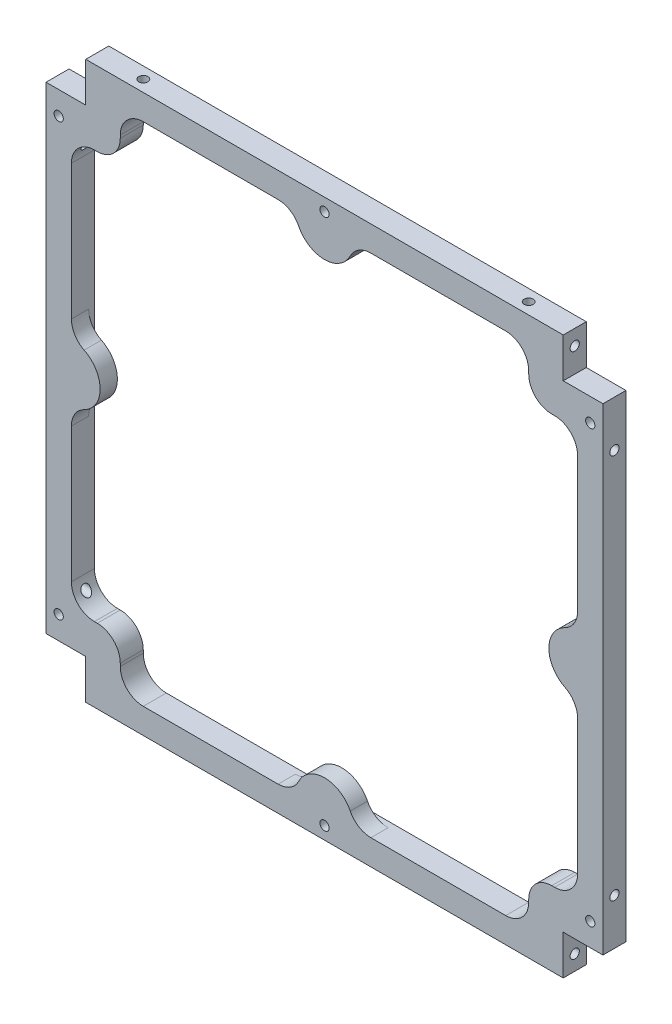
from build123d import *

# Parameters (mm, degrees)
SKETCH3_W                  = 100
SKETCH3_H                  = 100
BOSS_EXTRUDE2_DEPTH        = 4
SKETCH4_W                  = 8.5
SKETCH4_H                  = 8.5
CUT_EXTRUDE1_DEPTH         = 142.477913471
CUT_EXTRUDE2_DEPTH         = 142.477913471
FILLET4_R                  = 4
FILLET6_R                  = 4
BOSS_EXTRUDE3_DEPTH        = 3
M2X0_4_TAPPED_HOLE1_D      = 1.6
M2X0_4_TAPPED_HOLE1_DEPTH  = 5.2
M2X0_4_TAPPED_HOLE1_TIP    = 0.480688495
M2X0_4_TAPPED_HOLE2_REACH  = 143.478
M2X0_4_TAPPED_HOLE2_BORE_R = 0.8
M2X0_4_TAPPED_HOLE3_D      = 1.6
M2X0_4_TAPPED_HOLE3_DEPTH  = 8.52
M2X0_4_TAPPED_HOLE3_TIP    = 0.480688495
M2X0_4_TAPPED_HOLE13_D     = 1.6
M2X0_4_TAPPED_HOLE5_D      = 1.6
M2X0_4_TAPPED_HOLE5_DEPTH  = 6
M2X0_4_TAPPED_HOLE5_TIP    = 0.480688495
FILLET7_R                  = 4
FILLET8_R                  = 4
M2X0_4_TAPPED_HOLE9_D      = 1.6
M2X0_4_TAPPED_HOLE9_DEPTH  = 6
M2X0_4_TAPPED_HOLE9_TIP    = 0.480688495
M2X0_4_TAPPED_HOLE10_D     = 1.6
M2X0_4_TAPPED_HOLE10_DEPTH = 6
M2X0_4_TAPPED_HOLE10_TIP   = 0.480688495
SKETCH33_W                 = 83
SKETCH33_H                 = 1.6
SKETCH33_W_2               = 1.6
SKETCH33_H_2               = 83
CUT_EXTRUDE3_DEPTH         = 10
M2X0_4_TAPPED_HOLE11_D     = 1.6
M2X0_4_TAPPED_HOLE11_DEPTH = 6
M2X0_4_TAPPED_HOLE11_TIP   = 0.480688495
M2X0_4_TAPPED_HOLE12_D     = 1.6
M2X0_4_TAPPED_HOLE12_DEPTH = 6
M2X0_4_TAPPED_HOLE12_TIP   = 0.480688495


with BuildPart() as part:
    # Sketch3 → Boss-Extrude2 (new body)
    with BuildSketch(Plane.XY):
        with Locations((50, -50)):
            Rectangle(SKETCH3_W, SKETCH3_H)
    extrude(amount=BOSS_EXTRUDE2_DEPTH)

    # Sketch4 → Cut-Extrude1 (cut, through all)
    with BuildSketch(Plane(origin=(0, 0, 0), x_dir=(-1, 0, 0), z_dir=(0, 0, -1))):
        with Locations((-4.25, -95.75)):
            Rectangle(SKETCH4_W, SKETCH4_H)
        with Locations((-4.25, -4.25)):
            Rectangle(SKETCH4_W, SKETCH4_H)
        with Locations((-95.75, -4.25)):
            Rectangle(SKETCH4_W, SKETCH4_H)
        with Locations((-95.75, -95.75)):
            Rectangle(SKETCH4_W, SKETCH4_H)
    extrude(amount=-CUT_EXTRUDE1_DEPTH, mode=Mode.SUBTRACT)

    # Sketch5 → Cut-Extrude2 (cut, through all)
    with BuildSketch(Plane(origin=(0, 0, 0), x_dir=(-1, 0, 0), z_dir=(0, 0, -1))):
        Polygon((-94, -14.5), (-85.5, -14.5), (-85.5, -6), (-14.5, -6), (-14.5, -14.5), (-6, -14.5), (-6, -85.5), (-14.5, -85.5), (-14.5, -94), (-85.5, -94), (-85.5, -85.5), (-94, -85.5), align=None)
    extrude(amount=-CUT_EXTRUDE2_DEPTH, mode=Mode.SUBTRACT)

    # Fillet4
    fillet4_edges = [part.edges().sort_by_distance(p)[0] for p in [
        (85.5, -14.5, 2),
        (14.5, -14.5, 2),
        (14.5, -85.5, 2),
        (85.5, -85.5, 2),
    ]]
    fillet(fillet4_edges, radius=FILLET4_R)

    # Fillet6
    fillet6_edges = [part.edges().sort_by_distance(p)[0] for p in [
        (94, -85.5, 2),
        (94, -14.5, 2),
        (85.5, -6, 2),
        (14.5, -6, 2),
        (6, -14.5, 2),
        (6, -85.5, 2),
        (14.5, -94, 2),
        (85.5, -94, 2),
    ]]
    fillet(fillet6_edges, radius=FILLET6_R)

    # Sketch6 → Boss-Extrude3 (add)
    with BuildSketch(Plane.XY.offset(4)):
        with BuildLine():
            Line((6, -45), (6, -55))
            ThreePointArc((6, -55), (11, -50), (6, -45))
        make_face()
        with BuildLine():
            Line((94, -45), (94, -55))
            ThreePointArc((94, -55), (89, -50), (94, -45))
        make_face()
        with BuildLine():
            Line((45, -6), (55, -6))
            ThreePointArc((55, -6), (50, -11), (45, -6))
        make_face()
        with BuildLine():
            Line((45, -94), (55, -94))
            ThreePointArc((55, -94), (50, -89), (45, -94))
        make_face()
    extrude(amount=-BOSS_EXTRUDE3_DEPTH)

    # M2x0.4 Tapped Hole1
    with Locations(Plane.XY.offset(4)):
        with Locations((50, -3.8), (3.8, -12.5), (50, -96.2), (96.2, -87.5), (3.8, -87.5), (96.2, -12.5)):
            Hole(M2X0_4_TAPPED_HOLE1_D / 2, depth=M2X0_4_TAPPED_HOLE1_DEPTH)
            with Locations((0, 0, -(M2X0_4_TAPPED_HOLE1_DEPTH + M2X0_4_TAPPED_HOLE1_TIP / 2))):  # 118° drill point
                Cone(0, M2X0_4_TAPPED_HOLE1_D / 2, M2X0_4_TAPPED_HOLE1_TIP, mode=Mode.SUBTRACT)

    # M2x0.4 Tapped Hole2 bore → M2x0.4 Tapped Hole2 (cut, up to next)
    with BuildSketch(Plane(origin=(0, 0, 0), x_dir=(1, 0, 0), z_dir=(0, 1, 0)), mode=Mode.PRIVATE) as m2x0_4_tapped_hole2_sk1:
        with Locations((83.5, -2)):
            Circle(M2X0_4_TAPPED_HOLE2_BORE_R)
    m2x0_4_tapped_hole2_tool1 = extrude(m2x0_4_tapped_hole2_sk1.sketch, amount=-M2X0_4_TAPPED_HOLE2_REACH, mode=Mode.PRIVATE) & part.part
    # M2x0.4 Tapped Hole2 bore → M2x0.4 Tapped Hole2 (cut, up to next)
    with BuildSketch(Plane(origin=(0, 0, 0), x_dir=(1, 0, 0), z_dir=(0, 1, 0)), mode=Mode.PRIVATE) as m2x0_4_tapped_hole2_sk2:
        with Locations((16.5, -2)):
            Circle(M2X0_4_TAPPED_HOLE2_BORE_R)
    m2x0_4_tapped_hole2_tool2 = extrude(m2x0_4_tapped_hole2_sk2.sketch, amount=-M2X0_4_TAPPED_HOLE2_REACH, mode=Mode.PRIVATE) & part.part
    add(m2x0_4_tapped_hole2_tool1.solids().sort_by_distance((83.5, 0, 2))[0], mode=Mode.SUBTRACT)
    add(m2x0_4_tapped_hole2_tool2.solids().sort_by_distance((16.5, 0, 2))[0], mode=Mode.SUBTRACT)

    # M2x0.4 Tapped Hole3
    with Locations(Plane(origin=(100, 0, 0), x_dir=(0, 0, -1), z_dir=(1, 0, 0))):
        with Locations((-2, -83.5), (-2, -16.5)):
            Hole(M2X0_4_TAPPED_HOLE3_D / 2, depth=M2X0_4_TAPPED_HOLE3_DEPTH)
            with Locations((0, 0, -(M2X0_4_TAPPED_HOLE3_DEPTH + M2X0_4_TAPPED_HOLE3_TIP / 2))):  # 118° drill point
                Cone(0, M2X0_4_TAPPED_HOLE3_D / 2, M2X0_4_TAPPED_HOLE3_TIP, mode=Mode.SUBTRACT)

    # M2x0.4 Tapped Hole13 (through all)
    with Locations(Plane.ZY):
        with Locations((2, -83.5), (2, -16.5)):
            Hole(M2X0_4_TAPPED_HOLE13_D / 2)

    # M2x0.4 Tapped Hole5
    with Locations(Plane(origin=(0, -100, 0), x_dir=(-1, 0, 0), z_dir=(0, -1, 0))):
        with Locations((-16.5, -2), (-83.5, -2)):
            Hole(M2X0_4_TAPPED_HOLE5_D / 2, depth=M2X0_4_TAPPED_HOLE5_DEPTH)
            with Locations((0, 0, -(M2X0_4_TAPPED_HOLE5_DEPTH + M2X0_4_TAPPED_HOLE5_TIP / 2))):  # 118° drill point
                Cone(0, M2X0_4_TAPPED_HOLE5_D / 2, M2X0_4_TAPPED_HOLE5_TIP, mode=Mode.SUBTRACT)

    # Fillet7
    fillet7_edges = [part.edges().sort_by_distance(p)[0] for p in [
        (6, -45, 2.5),
    ]]
    fillet(fillet7_edges, radius=FILLET7_R)

    # Fillet8
    fillet8_edges = [part.edges().sort_by_distance(p)[0] for p in [
        (6, -55, 2.5),
        (94, -55, 2.5),
        (94, -45, 2.5),
        (55, -6, 2.5),
        (45, -6, 2.5),
        (45, -94, 2.5),
        (55, -94, 2.5),
    ]]
    fillet(fillet8_edges, radius=FILLET8_R)

    # M2x0.4 Tapped Hole9
    with Locations(Plane.ZY.offset(-8.5)):
        with Locations((2, -95.75)):
            Hole(M2X0_4_TAPPED_HOLE9_D / 2, depth=M2X0_4_TAPPED_HOLE9_DEPTH)
            with Locations((0, 0, -(M2X0_4_TAPPED_HOLE9_DEPTH + M2X0_4_TAPPED_HOLE9_TIP / 2))):  # 118° drill point
                Cone(0, M2X0_4_TAPPED_HOLE9_D / 2, M2X0_4_TAPPED_HOLE9_TIP, mode=Mode.SUBTRACT)

    # M2x0.4 Tapped Hole10
    with Locations(Plane.ZY.offset(-8.5)):
        with Locations((2, -4.25)):
            Hole(M2X0_4_TAPPED_HOLE10_D / 2, depth=M2X0_4_TAPPED_HOLE10_DEPTH)
            with Locations((0, 0, -(M2X0_4_TAPPED_HOLE10_DEPTH + M2X0_4_TAPPED_HOLE10_TIP / 2))):  # 118° drill point
                Cone(0, M2X0_4_TAPPED_HOLE10_D / 2, M2X0_4_TAPPED_HOLE10_TIP, mode=Mode.SUBTRACT)

    # Sketch33 → Cut-Extrude3 (cut)
    with BuildSketch(Plane.XY.offset(4)):
        with Locations((50, -99.2)):
            Rectangle(SKETCH33_W, SKETCH33_H)
        with Locations((99.2, -50)):
            Rectangle(SKETCH33_W_2, SKETCH33_H_2)
        with Locations((50, -0.8)):
            Rectangle(SKETCH33_W, SKETCH33_H)
        with Locations((0.8, -50)):
            Rectangle(SKETCH33_W_2, SKETCH33_H_2)
    extrude(amount=-CUT_EXTRUDE3_DEPTH, mode=Mode.SUBTRACT)

    # M2x0.4 Tapped Hole11
    with Locations(Plane(origin=(91.5, 0, 0), x_dir=(0, 0, -1), z_dir=(1, 0, 0))):
        with Locations((-2, -95.75)):
            Hole(M2X0_4_TAPPED_HOLE11_D / 2, depth=M2X0_4_TAPPED_HOLE11_DEPTH)
            with Locations((0, 0, -(M2X0_4_TAPPED_HOLE11_DEPTH + M2X0_4_TAPPED_HOLE11_TIP / 2))):  # 118° drill point
                Cone(0, M2X0_4_TAPPED_HOLE11_D / 2, M2X0_4_TAPPED_HOLE11_TIP, mode=Mode.SUBTRACT)

    # M2x0.4 Tapped Hole12
    with Locations(Plane(origin=(91.5, 0, 0), x_dir=(0, 0, -1), z_dir=(1, 0, 0))):
        with Locations((-2, -4.25)):
            Hole(M2X0_4_TAPPED_HOLE12_D / 2, depth=M2X0_4_TAPPED_HOLE12_DEPTH)
            with Locations((0, 0, -(M2X0_4_TAPPED_HOLE12_DEPTH + M2X0_4_TAPPED_HOLE12_TIP / 2))):  # 118° drill point
                Cone(0, M2X0_4_TAPPED_HOLE12_D / 2, M2X0_4_TAPPED_HOLE12_TIP, mode=Mode.SUBTRACT)


solid = part.part
